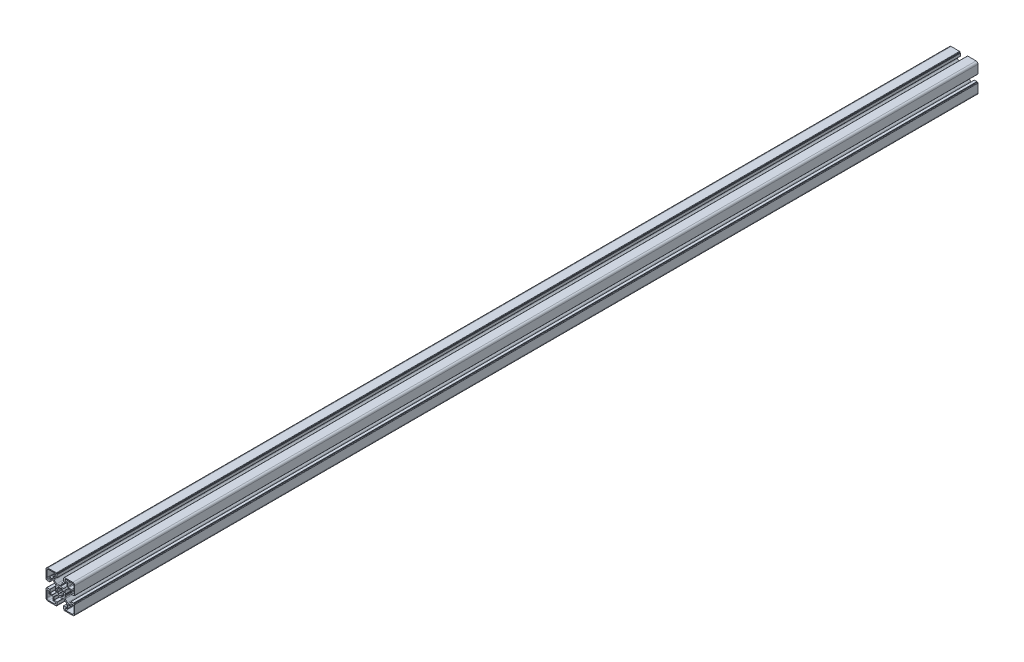
from build123d import *

# Parameters (mm, degrees)
BOSS_EXTRU_1_DEPTH = 1415


with BuildPart() as part:
    # Esquisse2 → Boss.-Extru.1 (new body)
    with BuildSketch(Plane.XY):
        with BuildLine():
            Line((-192.464705439, -351.135013575), (-192.030789329, -350.389251613))
            ThreePointArc((-192.030789329, -350.389251613), (-192.008099493, -350.33058749), (-192.004751867, -350.267777448))
            ThreePointArc((-192.004751867, -350.267777448), (-192.285035172, -348.883447185), (-192.804402464, -347.569983587))
            ThreePointArc((-192.804402464, -347.569983587), (-192.985908697, -346.38788866), (-192.44128198, -345.323147062))
            Line((-192.44128198, -345.323147062), (-188.874986025, -341.756855105))
            ThreePointArc((-188.874986025, -341.756855105), (-188.244141301, -341.335338521), (-187.500009401, -341.187321592))
            Line((-187.500009401, -341.187321592), (-183.687863463, -341.187321592))
            ThreePointArc((-183.687863463, -341.187321592), (-183.546441859, -341.245900338), (-183.487863113, -341.387321941))
            Line((-183.487863113, -341.387321941), (-183.487863113, -345.981828905))
            ThreePointArc((-183.487863113, -345.981828905), (-183.429284366, -346.12325051), (-183.287862762, -346.181829256))
            Line((-183.287862762, -346.181829256), (-179.285166009, -346.181829256))
            ThreePointArc((-179.285166009, -346.181829256), (-179.073034487, -346.093961503), (-178.985166733, -345.88182998))
            Line((-178.985166733, -345.88182998), (-178.985166733, -345.681839032))
            ThreePointArc((-178.985166733, -345.681839032), (-178.897298833, -345.469707156), (-178.685166958, -345.381839256))
            Line((-178.685166958, -345.381839256), (-178.0047864, -345.381839256))
            ThreePointArc((-178.0047864, -345.381839256), (-177.651233276, -345.235392756), (-177.504786776, -344.881839631))
            Line((-177.504786776, -344.881839631), (-177.504786776, -331.681827015))
            ThreePointArc((-177.504786776, -331.681827015), (-178.383465776, -329.560508257), (-180.504784534, -328.681829257))
            Line((-180.504784534, -328.681829257), (-193.629056903, -328.681829257))
            ThreePointArc((-193.629056903, -328.681829257), (-193.982610029, -328.828275756), (-194.129056529, -329.181828882))
            Line((-194.129056529, -329.181828882), (-194.129056529, -329.881829981))
            ThreePointArc((-194.129056529, -329.881829981), (-194.216924283, -330.093961503), (-194.429055805, -330.181829256))
            Line((-194.429055805, -330.181829256), (-194.70476714, -330.181829256))
            ThreePointArc((-194.70476714, -330.181829256), (-194.916898308, -330.269696863), (-195.004765915, -330.481828031))
            Line((-195.004765915, -330.481828031), (-195.004765915, -334.515030698))
            ThreePointArc((-195.004765915, -334.515030698), (-194.946187022, -334.656452656), (-194.804765065, -334.715031549))
            Line((-194.804765065, -334.715031549), (-190.099380697, -334.715031549))
            ThreePointArc((-190.099380697, -334.715031549), (-189.957959093, -334.773610295), (-189.899380347, -334.9150319))
            Line((-189.899380347, -334.9150319), (-189.899380347, -338.710260175))
            ThreePointArc((-189.899380347, -338.710260175), (-190.051621327, -339.47562727), (-190.48516696, -340.124474162))
            Line((-190.48516696, -340.124474162), (-194.059867926, -343.699175128))
            ThreePointArc((-194.059867926, -343.699175128), (-195.150164081, -344.214009408), (-196.338266679, -344.008553194))
            ThreePointArc((-196.338266679, -344.008553194), (-197.695629231, -343.467994797), (-199.128369878, -343.181829256))
            ThreePointArc((-199.128369878, -343.181829256), (-199.191201005, -343.184754557), (-199.250016338, -343.207049503))
            Line((-199.250016338, -343.207049503), (-199.892137456, -343.574906197))
            ThreePointArc((-199.892137456, -343.574906197), (-199.941802013, -343.622754392), (-200.004765916, -343.650889155))
            ThreePointArc((-200.004765916, -343.650889155), (-200.067729818, -343.622754392), (-200.117394375, -343.574906197))
            Line((-200.117394375, -343.574906197), (-200.759515492, -343.207049503))
            ThreePointArc((-200.759515492, -343.207049503), (-200.818330825, -343.184754557), (-200.881161953, -343.181829255))
            ThreePointArc((-200.881161953, -343.181829255), (-202.3139026, -343.467994797), (-203.671265152, -344.008553193))
            ThreePointArc((-203.671265152, -344.008553193), (-204.85936775, -344.214009407), (-205.949663904, -343.699175128))
            Line((-205.949663904, -343.699175128), (-209.52436487, -340.124474162))
            ThreePointArc((-209.52436487, -340.124474162), (-209.957910503, -339.475627269), (-210.110151485, -338.710260174))
            Line((-210.110151485, -338.710260174), (-210.110151485, -334.915031899))
            ThreePointArc((-210.110151485, -334.915031899), (-210.051572738, -334.773610295), (-209.910151134, -334.715031548))
            Line((-209.910151134, -334.715031548), (-205.204766766, -334.715031548))
            ThreePointArc((-205.204766766, -334.715031548), (-205.063344808, -334.656452656), (-205.004765915, -334.515030698))
            Line((-205.004765915, -334.515030698), (-205.004765915, -330.481828032))
            ThreePointArc((-205.004765915, -330.481828032), (-205.092633523, -330.269696863), (-205.304764692, -330.181829256))
            Line((-205.304764692, -330.181829256), (-205.580476025, -330.181829256))
            ThreePointArc((-205.580476025, -330.181829256), (-205.792607548, -330.093961502), (-205.880475302, -329.88182998))
            Line((-205.880475302, -329.88182998), (-205.880475302, -329.181828882))
            ThreePointArc((-205.880475302, -329.181828882), (-206.026921801, -328.828275756), (-206.380474927, -328.681829256))
            Line((-206.380474927, -328.681829256), (-219.504747296, -328.681829256))
            ThreePointArc((-219.504747296, -328.681829256), (-221.626066055, -329.560508256), (-222.504745055, -331.681827014))
            Line((-222.504745055, -331.681827014), (-222.504745055, -344.88183963))
            ThreePointArc((-222.504745055, -344.88183963), (-222.358298555, -345.235392756), (-222.00474543, -345.381839256))
            Line((-222.00474543, -345.381839256), (-221.324364871, -345.381839256))
            ThreePointArc((-221.324364871, -345.381839256), (-221.112232996, -345.469707157), (-221.024365096, -345.681839032))
            Line((-221.024365096, -345.681839032), (-221.024365096, -345.88182998))
            ThreePointArc((-221.024365096, -345.88182998), (-220.936497342, -346.093961503), (-220.724365819, -346.181829256))
            Line((-220.724365819, -346.181829256), (-216.721669067, -346.181829256))
            ThreePointArc((-216.721669067, -346.181829256), (-216.580247463, -346.12325051), (-216.521668717, -345.981828906))
            Line((-216.521668717, -345.981828906), (-216.521668717, -341.387321942))
            ThreePointArc((-216.521668717, -341.387321942), (-216.46308997, -341.245900338), (-216.321668366, -341.187321592))
            Line((-216.321668366, -341.187321592), (-212.509522428, -341.187321592))
            ThreePointArc((-212.509522428, -341.187321592), (-211.765390527, -341.335338522), (-211.134545803, -341.756855106))
            Line((-211.134545803, -341.756855106), (-207.568249848, -345.323147062))
            ThreePointArc((-207.568249848, -345.323147062), (-207.023623131, -346.38788866), (-207.205129364, -347.569983588))
            ThreePointArc((-207.205129364, -347.569983588), (-207.724496656, -348.883447186), (-208.004779961, -350.267777448))
            ThreePointArc((-208.004779961, -350.267777448), (-208.001432335, -350.33058749), (-207.978742499, -350.389251614))
            Line((-207.978742499, -350.389251614), (-207.54482639, -351.135013575))
            ThreePointArc((-207.54482639, -351.135013575), (-207.5390619, -351.158167493), (-207.536095855, -351.181843132))
            ThreePointArc((-207.536095855, -351.181843132), (-207.5390619, -351.20551877), (-207.54482639, -351.228672687))
            Line((-207.54482639, -351.228672687), (-207.978742499, -351.974434649))
            ThreePointArc((-207.978742499, -351.974434649), (-208.001432335, -352.033098773), (-208.004779962, -352.095908815))
            ThreePointArc((-208.004779962, -352.095908815), (-207.724496656, -353.480239077), (-207.205129364, -354.793702675))
            ThreePointArc((-207.205129364, -354.793702675), (-207.023623132, -355.975797603), (-207.568249848, -357.040539202))
            Line((-207.568249848, -357.040539202), (-211.134545804, -360.606831158))
            ThreePointArc((-211.134545804, -360.606831158), (-211.765390528, -361.028347742), (-212.509522429, -361.176364671))
            Line((-212.509522429, -361.176364671), (-216.321668366, -361.176364671))
            ThreePointArc((-216.321668366, -361.176364671), (-216.463089971, -361.117785925), (-216.521668717, -360.97636432))
            Line((-216.521668717, -360.97636432), (-216.521668717, -356.381857357))
            ThreePointArc((-216.521668717, -356.381857357), (-216.580247463, -356.240435753), (-216.721669067, -356.181857007))
            Line((-216.721669067, -356.181857007), (-220.72436582, -356.181857007))
            ThreePointArc((-220.72436582, -356.181857007), (-220.936497342, -356.26972476), (-221.024365096, -356.481856283))
            Line((-221.024365096, -356.481856283), (-221.024365096, -356.68184723))
            ThreePointArc((-221.024365096, -356.68184723), (-221.112232996, -356.893979106), (-221.324364871, -356.981847005))
            Line((-221.324364871, -356.981847005), (-222.004745429, -356.981847005))
            ThreePointArc((-222.004745429, -356.981847005), (-222.358298555, -357.128293506), (-222.504745055, -357.481846632))
            Line((-222.504745055, -357.481846632), (-222.504745055, -370.681859247))
            ThreePointArc((-222.504745055, -370.681859247), (-221.626066055, -372.803178006), (-219.504747296, -373.681857006))
            Line((-219.504747296, -373.681857006), (-206.380474927, -373.681857006))
            ThreePointArc((-206.380474927, -373.681857006), (-206.026921801, -373.535410506), (-205.880475301, -373.18185738))
            Line((-205.880475301, -373.18185738), (-205.880475301, -372.481856282))
            ThreePointArc((-205.880475301, -372.481856282), (-205.792607548, -372.269724759), (-205.580476025, -372.181857005))
            Line((-205.580476025, -372.181857005), (-205.304764691, -372.181857005))
            ThreePointArc((-205.304764691, -372.181857005), (-205.092633522, -372.093989398), (-205.004765915, -371.881858229))
            Line((-205.004765915, -371.881858229), (-205.004765915, -367.848655563))
            ThreePointArc((-205.004765915, -367.848655563), (-205.063344808, -367.707233605), (-205.204766766, -367.648654712))
            Line((-205.204766766, -367.648654712), (-209.910151134, -367.648654712))
            ThreePointArc((-209.910151134, -367.648654712), (-210.051572738, -367.590075966), (-210.110151485, -367.448654362))
            Line((-210.110151485, -367.448654362), (-210.110151485, -363.653426086))
            ThreePointArc((-210.110151485, -363.653426086), (-209.957910503, -362.888058992), (-209.524364871, -362.239212099))
            Line((-209.524364871, -362.239212099), (-205.949663905, -358.664511133))
            ThreePointArc((-205.949663905, -358.664511133), (-204.85936775, -358.149676855), (-203.671265152, -358.355133067))
            ThreePointArc((-203.671265152, -358.355133067), (-202.3139026, -358.895691464), (-200.881161954, -359.181857005))
            ThreePointArc((-200.881161954, -359.181857005), (-200.818330826, -359.178931703), (-200.759515493, -359.156636757))
            Line((-200.759515493, -359.156636757), (-200.117394376, -358.788780064))
            ThreePointArc((-200.117394376, -358.788780064), (-200.067729819, -358.740931869), (-200.004765916, -358.712797106))
            ThreePointArc((-200.004765916, -358.712797106), (-199.941802013, -358.740931869), (-199.892137456, -358.788780064))
            Line((-199.892137456, -358.788780064), (-199.250016339, -359.156636758))
            ThreePointArc((-199.250016339, -359.156636758), (-199.191201006, -359.178931704), (-199.128369878, -359.181857005))
            ThreePointArc((-199.128369878, -359.181857005), (-197.695629231, -358.895691464), (-196.338266679, -358.355133068))
            ThreePointArc((-196.338266679, -358.355133068), (-195.150164082, -358.149676855), (-194.059867927, -358.664511133))
            Line((-194.059867927, -358.664511133), (-190.48516696, -362.239212099))
            ThreePointArc((-190.48516696, -362.239212099), (-190.051621328, -362.888058992), (-189.899380348, -363.653426086))
            Line((-189.899380348, -363.653426086), (-189.899380348, -367.448654362))
            ThreePointArc((-189.899380348, -367.448654362), (-189.957959094, -367.590075965), (-190.099380697, -367.648654712))
            Line((-190.099380697, -367.648654712), (-194.804765066, -367.648654712))
            ThreePointArc((-194.804765066, -367.648654712), (-194.946187023, -367.707233605), (-195.004765916, -367.848655563))
            Line((-195.004765916, -367.848655563), (-195.004765916, -371.881858229))
            ThreePointArc((-195.004765916, -371.881858229), (-194.916898309, -372.093989397), (-194.70476714, -372.181857004))
            Line((-194.70476714, -372.181857004), (-194.429055806, -372.181857004))
            ThreePointArc((-194.429055806, -372.181857004), (-194.216924283, -372.269724758), (-194.12905653, -372.48185628))
            Line((-194.12905653, -372.48185628), (-194.12905653, -373.181857379))
            ThreePointArc((-194.12905653, -373.181857379), (-193.98261003, -373.535410505), (-193.629056903, -373.681857006))
            Line((-193.629056903, -373.681857006), (-180.504784534, -373.681857006))
            ThreePointArc((-180.504784534, -373.681857006), (-178.383465775, -372.803178005), (-177.504786775, -370.681859246))
            Line((-177.504786775, -370.681859246), (-177.504786775, -357.481846631))
            ThreePointArc((-177.504786775, -357.481846631), (-177.651233275, -357.128293504), (-178.004786402, -356.981847004))
            Line((-178.004786402, -356.981847004), (-178.685166959, -356.981847004))
            ThreePointArc((-178.685166959, -356.981847004), (-178.897298836, -356.893979105), (-178.985166735, -356.681847228))
            Line((-178.985166735, -356.681847228), (-178.985166735, -356.481856281))
            ThreePointArc((-178.985166735, -356.481856281), (-179.073034488, -356.269724759), (-179.28516601, -356.181857005))
            Line((-179.28516601, -356.181857005), (-183.287862762, -356.181857005))
            ThreePointArc((-183.287862762, -356.181857005), (-183.429284367, -356.240435752), (-183.487863113, -356.381857356))
            Line((-183.487863113, -356.381857356), (-183.487863113, -360.97636432))
            ThreePointArc((-183.487863113, -360.97636432), (-183.546441859, -361.117785924), (-183.687863463, -361.176364671))
            Line((-183.687863463, -361.176364671), (-187.500009401, -361.176364671))
            ThreePointArc((-187.500009401, -361.176364671), (-188.244141302, -361.028347742), (-188.874986026, -360.606831157))
            Line((-188.874986026, -360.606831157), (-192.441281982, -357.040539201))
            ThreePointArc((-192.441281982, -357.040539201), (-192.985908698, -355.975797602), (-192.804402465, -354.793702674))
            ThreePointArc((-192.804402465, -354.793702674), (-192.285035173, -353.480239077), (-192.004751867, -352.095908814))
            ThreePointArc((-192.004751867, -352.095908814), (-192.008099493, -352.033098772), (-192.030789329, -351.974434649))
            Line((-192.030789329, -351.974434649), (-192.464705438, -351.228672687))
            ThreePointArc((-192.464705438, -351.228672687), (-192.47046993, -351.20551877), (-192.473435973, -351.181843131))
            ThreePointArc((-192.473435973, -351.181843131), (-192.47046993, -351.158167492), (-192.464705439, -351.135013575))
        make_face()
        with BuildLine():
            Line((-195.08422015, -352.069665956), (-194.515035218, -352.16805429))
            ThreePointArc((-194.515035218, -352.16805429), (-194.165013852, -352.386136153), (-194.09791825, -352.793042574))
            ThreePointArc((-194.09791825, -352.793042574), (-194.353505931, -353.535154011), (-194.702268027, -354.238303673))
            ThreePointArc((-194.702268027, -354.238303673), (-195.035805071, -354.480613812), (-195.437988264, -354.390005633))
            Line((-195.437988264, -354.390005633), (-195.915053025, -354.058342475))
            ThreePointArc((-195.915053025, -354.058342475), (-196.474632965, -354.722769754), (-197.140765494, -355.280318651))
            Line((-197.140765494, -355.280318651), (-196.813454008, -355.744441346))
            ThreePointArc((-196.813454008, -355.744441346), (-196.720150548, -356.146118205), (-196.960380945, -356.481288596))
            ThreePointArc((-196.960380945, -356.481288596), (-197.665869942, -356.825320826), (-198.409694498, -357.075915978))
            ThreePointArc((-198.409694498, -357.075915978), (-198.816910196, -357.011432294), (-199.037244235, -356.662956066))
            Line((-199.037244235, -356.662956066), (-199.137377178, -356.106032077))
            ThreePointArc((-199.137377178, -356.106032077), (-200.004765915, -356.181843131), (-200.872154653, -356.106032077))
            Line((-200.872154653, -356.106032077), (-200.972287596, -356.662956066))
            ThreePointArc((-200.972287596, -356.662956066), (-201.192621634, -357.011432294), (-201.599837332, -357.075915978))
            ThreePointArc((-201.599837332, -357.075915978), (-202.343661888, -356.825320826), (-203.049150885, -356.481288596))
            ThreePointArc((-203.049150885, -356.481288596), (-203.289381283, -356.146118205), (-203.196077822, -355.744441346))
            Line((-203.196077822, -355.744441346), (-202.868766337, -355.280318651))
            ThreePointArc((-202.868766337, -355.280318651), (-203.534898866, -354.722769754), (-204.094478805, -354.058342475))
            Line((-204.094478805, -354.058342475), (-204.571543566, -354.390005633))
            ThreePointArc((-204.571543566, -354.390005633), (-204.97372676, -354.480613812), (-205.307263804, -354.238303673))
            ThreePointArc((-205.307263804, -354.238303673), (-205.6560259, -353.535154011), (-205.91161358, -352.793042574))
            ThreePointArc((-205.91161358, -352.793042574), (-205.844517979, -352.386136153), (-205.494496613, -352.16805429))
            Line((-205.494496613, -352.16805429), (-204.925311681, -352.069665956))
            ThreePointArc((-204.925311681, -352.069665956), (-205.004765916, -351.18184313), (-204.925311681, -350.294020305))
            Line((-204.925311681, -350.294020305), (-205.494496613, -350.195631971))
            ThreePointArc((-205.494496613, -350.195631971), (-205.844517979, -349.977550108), (-205.91161358, -349.570643686))
            ThreePointArc((-205.91161358, -349.570643686), (-205.6560259, -348.82853225), (-205.307263804, -348.125382588))
            ThreePointArc((-205.307263804, -348.125382588), (-204.97372676, -347.883072448), (-204.571543566, -347.973680627))
            Line((-204.571543566, -347.973680627), (-204.094478805, -348.305343785))
            ThreePointArc((-204.094478805, -348.305343785), (-203.534898866, -347.640916506), (-202.868766337, -347.08336761))
            Line((-202.868766337, -347.08336761), (-203.196077822, -346.619244915))
            ThreePointArc((-203.196077822, -346.619244915), (-203.289381283, -346.217568056), (-203.049150885, -345.882397665))
            ThreePointArc((-203.049150885, -345.882397665), (-202.343661888, -345.538365434), (-201.599837332, -345.287770282))
            ThreePointArc((-201.599837332, -345.287770282), (-201.192621634, -345.352253967), (-200.972287596, -345.700730195))
            Line((-200.972287596, -345.700730195), (-200.872154653, -346.257654184))
            ThreePointArc((-200.872154653, -346.257654184), (-200.004765915, -346.18184313), (-199.137377178, -346.257654184))
            Line((-199.137377178, -346.257654184), (-199.037244235, -345.700730195))
            ThreePointArc((-199.037244235, -345.700730195), (-198.816910196, -345.352253967), (-198.409694498, -345.287770282))
            ThreePointArc((-198.409694498, -345.287770282), (-197.665869942, -345.538365434), (-196.960380945, -345.882397665))
            ThreePointArc((-196.960380945, -345.882397665), (-196.720150548, -346.217568056), (-196.813454008, -346.619244915))
            Line((-196.813454008, -346.619244915), (-197.140765494, -347.08336761))
            ThreePointArc((-197.140765494, -347.08336761), (-196.474632965, -347.640916506), (-195.915053025, -348.305343785))
            Line((-195.915053025, -348.305343785), (-195.437988264, -347.973680627))
            ThreePointArc((-195.437988264, -347.973680627), (-195.035805071, -347.883072448), (-194.702268027, -348.125382588))
            ThreePointArc((-194.702268027, -348.125382588), (-194.353505931, -348.82853225), (-194.09791825, -349.570643686))
            ThreePointArc((-194.09791825, -349.570643686), (-194.165013852, -349.977550108), (-194.515035218, -350.195631971))
            Line((-194.515035218, -350.195631971), (-195.08422015, -350.294020305))
            ThreePointArc((-195.08422015, -350.294020305), (-195.004765915, -351.18184313), (-195.08422015, -352.069665956))
        make_face(mode=Mode.SUBTRACT)
        with BuildLine():
            Line((-191.004786777, -330.181829255), (-181.504784909, -330.181829255))
            ThreePointArc((-181.504784909, -330.181829255), (-179.737019277, -330.914061756), (-179.004786777, -332.681827388))
            Line((-179.004786777, -332.681827388), (-179.004786777, -342.181638256))
            ThreePointArc((-179.004786777, -342.181638256), (-180.504786777, -343.681638255), (-182.004786777, -342.181638255))
            Line((-182.004786777, -342.181638255), (-182.004786777, -340.631829508))
            ThreePointArc((-182.004786777, -340.631829508), (-182.297679777, -339.924723255), (-183.00478603, -339.631830255))
            Line((-183.00478603, -339.631830255), (-187.454788523, -339.631830255))
            ThreePointArc((-187.454788523, -339.631830255), (-188.161894777, -339.338937255), (-188.454787777, -338.631831002))
            Line((-188.454787777, -338.631831002), (-188.454787777, -334.181828508))
            ThreePointArc((-188.454787777, -334.181828508), (-188.747680777, -333.474722255), (-189.45478703, -333.181829255))
            Line((-189.45478703, -333.181829255), (-191.004786777, -333.181829255))
            ThreePointArc((-191.004786777, -333.181829255), (-192.504786777, -331.681829255), (-191.004786777, -330.181829255))
        make_face(mode=Mode.SUBTRACT)
        with BuildLine():
            Line((-221.004745053, -332.681827388), (-221.004745053, -342.181638256))
            ThreePointArc((-221.004745053, -342.181638256), (-219.504745053, -343.681638255), (-218.004745054, -342.181638255))
            Line((-218.004745054, -342.181638255), (-218.004745054, -340.631829508))
            ThreePointArc((-218.004745054, -340.631829508), (-217.711852054, -339.924723255), (-217.0047458, -339.631830255))
            Line((-217.0047458, -339.631830255), (-212.554743307, -339.631830255))
            ThreePointArc((-212.554743307, -339.631830255), (-211.847637054, -339.338937255), (-211.554744054, -338.631831002))
            Line((-211.554744054, -338.631831002), (-211.554744054, -334.181828508))
            ThreePointArc((-211.554744054, -334.181828508), (-211.261851054, -333.474722255), (-210.554744801, -333.181829255))
            Line((-210.554744801, -333.181829255), (-209.004745053, -333.181829255))
            ThreePointArc((-209.004745053, -333.181829255), (-207.504745054, -331.681829255), (-209.004745053, -330.181829255))
            Line((-209.004745053, -330.181829255), (-218.504746922, -330.181829255))
            ThreePointArc((-218.504746922, -330.181829255), (-220.272512554, -330.914061756), (-221.004745053, -332.681827388))
        make_face(mode=Mode.SUBTRACT)
        with BuildLine():
            Line((-191.004786777, -372.181857005), (-181.504784909, -372.181857005))
            ThreePointArc((-181.504784909, -372.181857005), (-179.737019277, -371.449624505), (-179.004786777, -369.681858873))
            Line((-179.004786777, -369.681858873), (-179.004786777, -360.182048004))
            ThreePointArc((-179.004786777, -360.182048004), (-180.504786777, -358.682048005), (-182.004786777, -360.182048005))
            Line((-182.004786777, -360.182048005), (-182.004786777, -361.731856752))
            ThreePointArc((-182.004786777, -361.731856752), (-182.297679777, -362.438963006), (-183.00478603, -362.731856006))
            Line((-183.00478603, -362.731856006), (-187.454788523, -362.731856006))
            ThreePointArc((-187.454788523, -362.731856006), (-188.161894777, -363.024749005), (-188.454787777, -363.731855258))
            Line((-188.454787777, -363.731855258), (-188.454787777, -368.181857752))
            ThreePointArc((-188.454787777, -368.181857752), (-188.747680777, -368.888964005), (-189.45478703, -369.181857005))
            Line((-189.45478703, -369.181857005), (-191.004786777, -369.181857005))
            ThreePointArc((-191.004786777, -369.181857005), (-192.504786777, -370.681857005), (-191.004786777, -372.181857005))
        make_face(mode=Mode.SUBTRACT)
        with BuildLine():
            Line((-209.004745053, -372.181857005), (-218.504746922, -372.181857005))
            ThreePointArc((-218.504746922, -372.181857005), (-220.272512554, -371.449624505), (-221.004745053, -369.681858873))
            Line((-221.004745053, -369.681858873), (-221.004745053, -360.182048004))
            ThreePointArc((-221.004745053, -360.182048004), (-219.504745053, -358.682048005), (-218.004745054, -360.182048005))
            Line((-218.004745054, -360.182048005), (-218.004745054, -361.731856752))
            ThreePointArc((-218.004745054, -361.731856752), (-217.711852054, -362.438963006), (-217.0047458, -362.731856006))
            Line((-217.0047458, -362.731856006), (-212.554743307, -362.731856006))
            ThreePointArc((-212.554743307, -362.731856006), (-211.847637054, -363.024749005), (-211.554744054, -363.731855258))
            Line((-211.554744054, -363.731855258), (-211.554744054, -368.181857752))
            ThreePointArc((-211.554744054, -368.181857752), (-211.261851054, -368.888964005), (-210.554744801, -369.181857005))
            Line((-210.554744801, -369.181857005), (-209.004745053, -369.181857005))
            ThreePointArc((-209.004745053, -369.181857005), (-207.504745054, -370.681857005), (-209.004745053, -372.181857005))
        make_face(mode=Mode.SUBTRACT)
    extrude(amount=BOSS_EXTRU_1_DEPTH)


solid = part.part
